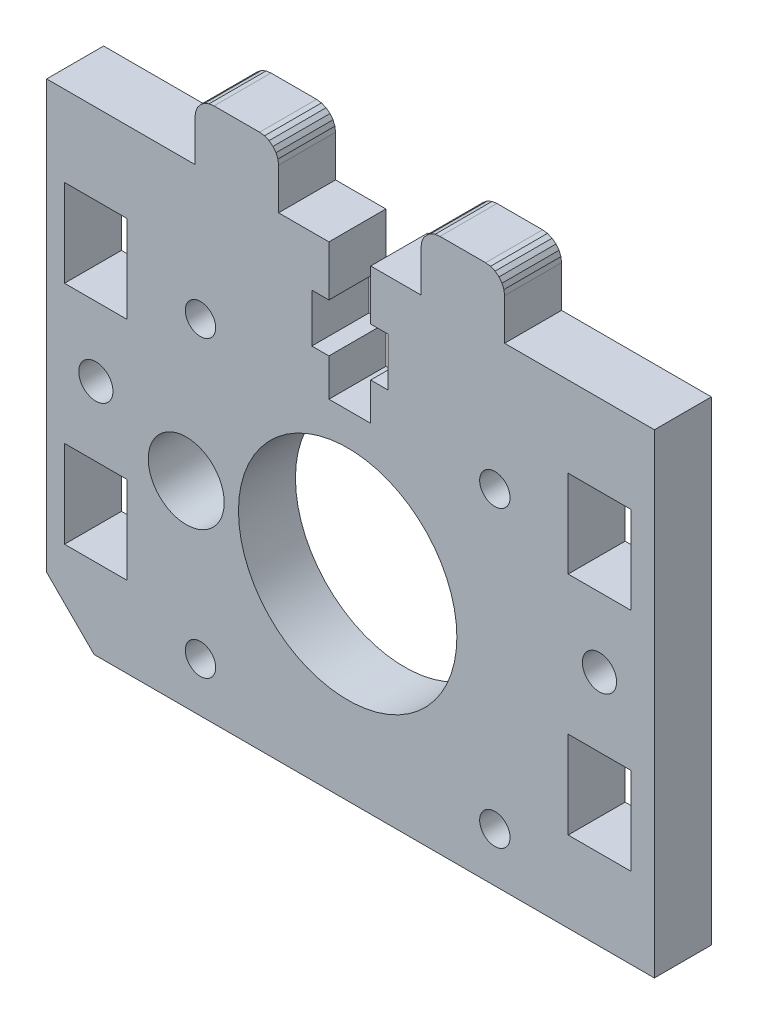
from build123d import *

# Parameters (mm, degrees)
MODEL_R                  = 1.6
MODEL_R_2                = 1.8
MODEL_R_3                = 4
MODEL_R_4                = 11.5
MODEL_W                  = 6.599987016
MODEL_H                  = 9.199995837
MODEL_W_2                = 6.600001917
MODEL_H_2                = 9.1999977
RESSALTO_EXTRUS_O1_DEPTH = 6


with BuildPart() as part:
    # Model → Ressalto-extrusão1 (new body)
    with BuildSketch(Plane.XY):
        Polygon((68.160504095, 58.4189533), (68.160504095, 53.118954478), (69.960502327, 53.118954478), (69.960502327, 48.018956714), (68.160504095, 48.018956714), (68.160504095, 44.068956891), (63.760499423, 44.068956891), (63.760499423, 48.018956714), (61.960501191, 48.018956714), (61.960501191, 53.118954478), (63.760499423, 53.118954478), (63.760499423, 58.4189533), (58.460502168, 58.4189533), (58.460502168, 62.768951191), (58.392353821, 63.286589281), (58.192552976, 63.768951191), (57.874715731, 64.183164754), (57.460502168, 64.501001999), (56.978140258, 64.700802844), (56.460502168, 64.768951191), (51.660507726, 64.768951191), (51.142869636, 64.700802844), (50.660507726, 64.501001999), (50.246294164, 64.183164754), (49.928456918, 63.768951191), (49.728656073, 63.286589281), (49.660507726, 62.768951191), (49.660507726, 58.4189533), (34.035520335, 58.4189533), (34.035520335, 13.418967617), (39.035518735, 8.418969217), (98.035493414, 8.418969027), (98.035488298, 58.4189533), (82.260492067, 58.4189533), (82.260492067, 62.768951191), (82.192343719, 63.286589281), (81.992542874, 63.768951191), (81.674705629, 64.183164754), (81.260492067, 64.501001999), (80.778130157, 64.700802844), (80.260492067, 64.768951191), (75.460496102, 64.768951191), (74.942858011, 64.700802844), (74.460496102, 64.501001999), (74.046282539, 64.183164754), (73.728445294, 63.768951191), (73.528644449, 63.286589281), (73.460496102, 62.768951191), (73.460496102, 58.4189533), align=None)
        with Locations((50.235508479, 44.618957639)):
            Circle(MODEL_R, mode=Mode.SUBTRACT)
        with Locations((50.235508479, 13.618967559)):
            Circle(MODEL_R, mode=Mode.SUBTRACT)
        with Locations((81.235498559, 13.618967559)):
            Circle(MODEL_R, mode=Mode.SUBTRACT)
        with Locations((81.235498559, 44.618957639)):
            Circle(MODEL_R, mode=Mode.SUBTRACT)
        with Locations((92.255495512, 33.418961223)):
            Circle(MODEL_R_2, mode=Mode.SUBTRACT)
        with Locations((39.215511525, 33.418961223)):
            Circle(MODEL_R_2, mode=Mode.SUBTRACT)
        with Locations((48.735508959, 29.118962599)):
            Circle(MODEL_R_3, mode=Mode.SUBTRACT)
        with Locations((65.735503519, 29.118962599)):
            Circle(MODEL_R_4, mode=Mode.SUBTRACT)
        with Locations((92.255493633, 45.318957274)):
            Rectangle(MODEL_W, MODEL_H, mode=Mode.SUBTRACT)
        with Locations((39.215512485, 45.318957274)):
            Rectangle(MODEL_W_2, MODEL_H, mode=Mode.SUBTRACT)
        with Locations((39.215512485, 21.518966444)):
            Rectangle(MODEL_W_2, MODEL_H_2, mode=Mode.SUBTRACT)
        with Locations((92.255493633, 21.518966444)):
            Rectangle(MODEL_W, MODEL_H_2, mode=Mode.SUBTRACT)
    extrude(amount=RESSALTO_EXTRUS_O1_DEPTH)


solid = part.part
